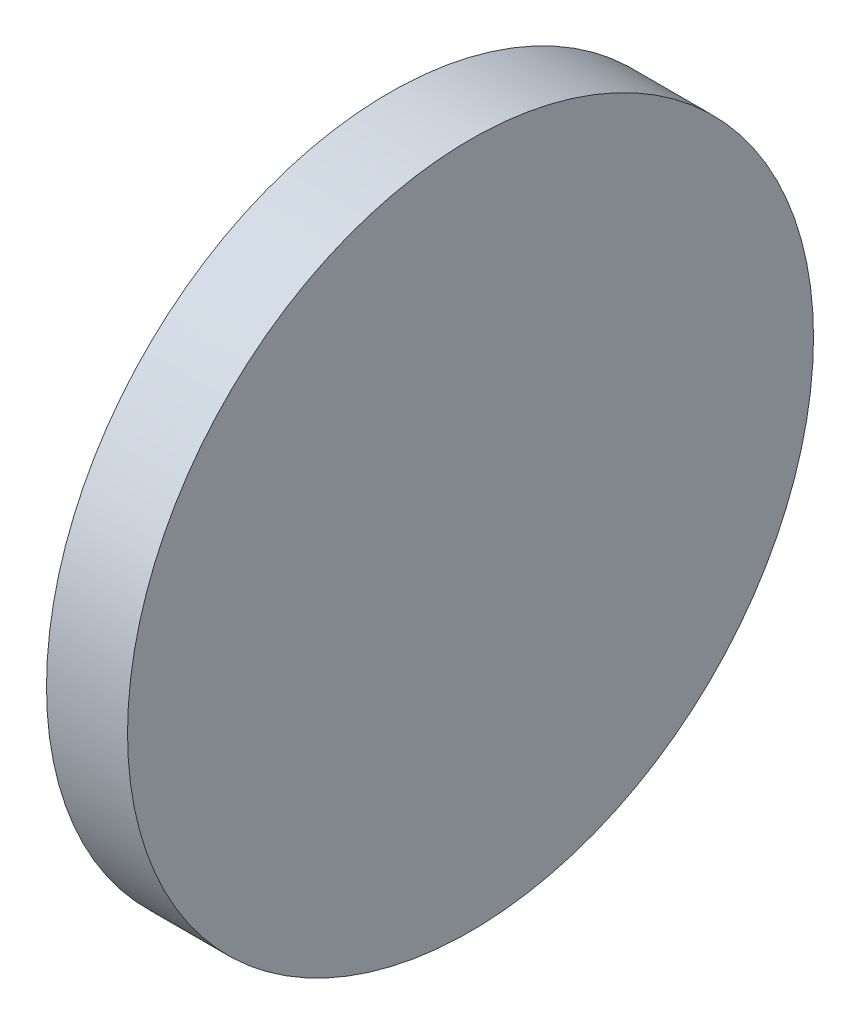
from build123d import *

# Parameters (mm, degrees)
SKETCH_1_W = 3
SKETCH_1_H = 12.7


with BuildPart() as part:
    # 草图1 → 旋转2 (revolve)
    with BuildSketch(Plane.XY, mode=Mode.PRIVATE) as revolve_2_sk:
        with Locations((1.5, 6.35)):
            Rectangle(SKETCH_1_W, SKETCH_1_H)
    revolve(revolve_2_sk.sketch.rotate(Axis((0, 0, 0), (1, 0, 0)), 90), axis=Axis((0, 0, 0), (1, 0, 0)))  # turned: the seam where the file's is


solid = part.part
